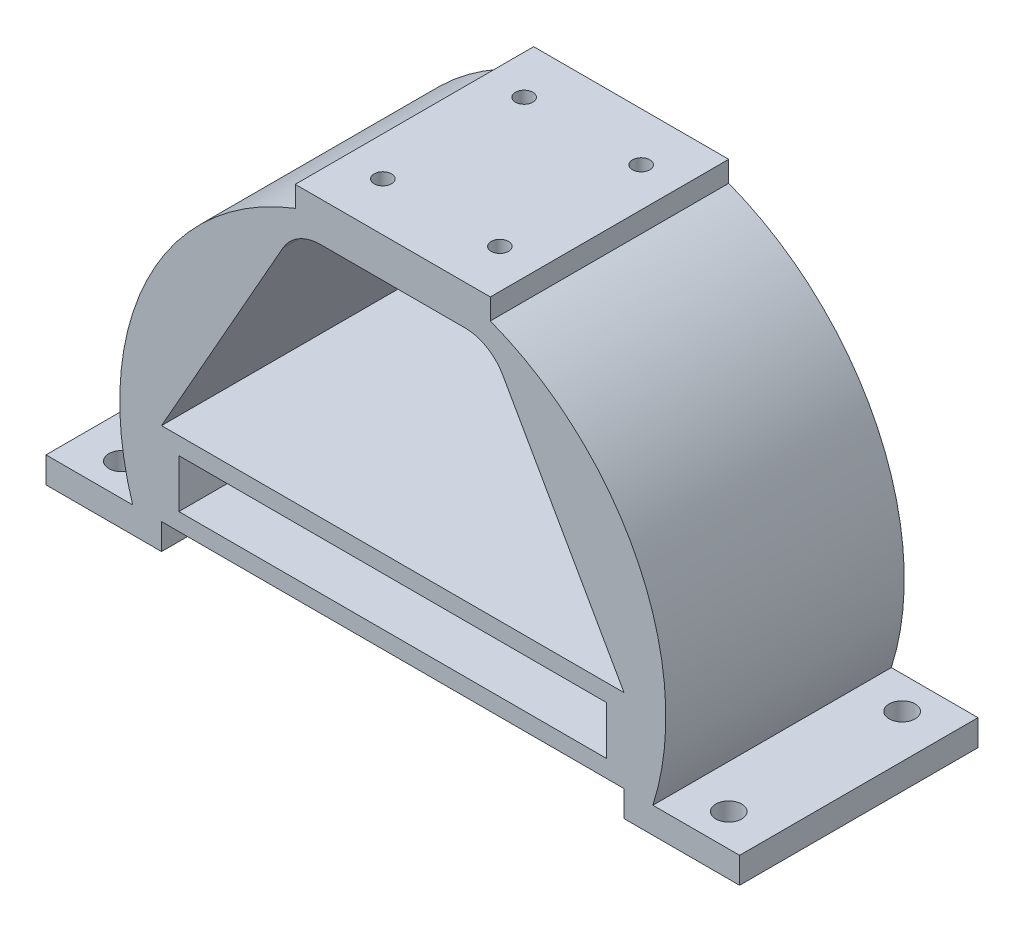
from build123d import *

# Parameters (mm, degrees)
BOSS_EXTRUDE1_DEPTH = 69.85
SKETCH2_W           = 135.505629996
SKETCH2_H           = 24.343701923
SKETCH2_W_2         = 125.345629996
SKETCH2_H_2         = 14.183701923
BOSS_EXTRUDE2_DEPTH = 69.85
CUT_EXTRUDE1_REACH  = 169.093
SKETCH3_R           = 3.81
CUT_EXTRUDE2_REACH  = 169.093
FILLET1_R           = 12.7


with BuildPart() as part:
    # Sketch1 → Boss-Extrude1 (new body)
    with BuildSketch(Plane.XY):
        with BuildLine():
            ThreePointArc((-28.575, 101.213911712), (-14.56545796, 105.448187464), (0, 106.877800601))
            Line((0, 106.877800601), (0, 112.776))
            Line((0, 112.776), (-28.575, 112.776))
            Line((-28.575, 112.776), (-28.575, 106.68))
            ThreePointArc((-28.575, 106.68), (-72.094875381, 66.624699703), (-76.2, 7.62))
            Line((-76.2, 7.62), (-101.6, 7.62))
            Line((-101.6, 7.62), (-101.6, 0))
            Line((-101.6, 0), (-67.752814998, 0))
            ThreePointArc((-67.752814998, 0), (-74.914098678, 31.963701923), (-67.752814998, 63.927403846))
            ThreePointArc((-67.752814998, 63.927403846), (-51.64622835, 86.229614594), (-28.575, 101.213911712))
        make_face()
        with BuildLine():
            Line((67.752814998, 0), (101.6, 0))
            Line((101.6, 0), (101.6, 7.62))
            Line((101.6, 7.62), (76.2, 7.62))
            ThreePointArc((76.2, 7.62), (72.094875381, 66.624699703), (28.575, 106.68))
            Line((28.575, 106.68), (28.575, 112.776))
            Line((28.575, 112.776), (0, 112.776))
            Line((0, 112.776), (0, 106.877800601))
            ThreePointArc((0, 106.877800601), (14.56545796, 105.448187464), (28.575, 101.213911712))
            ThreePointArc((28.575, 101.213911712), (51.64622835, 86.229614594), (67.752814998, 63.927403846))
            ThreePointArc((67.752814998, 63.927403846), (74.914098678, 31.963701923), (67.752814998, 0))
        make_face()
        with BuildLine():
            Line((28.575, 101.213911712), (67.752814998, 31.963701923))
            Line((67.752814998, 31.963701923), (67.752814998, 63.927403846))
            ThreePointArc((67.752814998, 63.927403846), (51.64622835, 86.229614594), (28.575, 101.213911712))
        make_face()
        with BuildLine():
            Line((0, 101.213911712), (28.575, 101.213911712))
            ThreePointArc((28.575, 101.213911712), (14.56545796, 105.448187464), (0, 106.877800601))
            Line((0, 106.877800601), (0, 101.213911712))
        make_face()
        with BuildLine():
            Line((-28.575, 101.213911712), (0, 101.213911712))
            Line((0, 101.213911712), (0, 106.877800601))
            ThreePointArc((0, 106.877800601), (-14.56545796, 105.448187464), (-28.575, 101.213911712))
        make_face()
        with BuildLine():
            Line((-67.752814998, 31.963701923), (-28.575, 101.213911712))
            ThreePointArc((-28.575, 101.213911712), (-51.64622835, 86.229614594), (-67.752814998, 63.927403846))
            Line((-67.752814998, 63.927403846), (-67.752814998, 31.963701923))
        make_face()
        with BuildLine():
            Line((-67.752814998, 0), (-67.752814998, 31.963701923))
            Line((-67.752814998, 31.963701923), (-67.752814998, 63.927403846))
            ThreePointArc((-67.752814998, 63.927403846), (-74.914098678, 31.963701923), (-67.752814998, 0))
        make_face()
        with BuildLine():
            Line((67.752814998, 31.963701923), (67.752814998, 0))
            ThreePointArc((67.752814998, 0), (74.914098678, 31.963701923), (67.752814998, 63.927403846))
            Line((67.752814998, 63.927403846), (67.752814998, 31.963701923))
        make_face()
    extrude(amount=BOSS_EXTRUDE1_DEPTH)

    # Sketch2 → Boss-Extrude2 (add)
    with BuildSketch(Plane.XY.offset(69.85)):
        with Locations((0, 19.791850961)):
            Rectangle(SKETCH2_W, SKETCH2_H)
        with Locations((0, 19.791850961)):
            Rectangle(SKETCH2_W_2, SKETCH2_H_2, mode=Mode.SUBTRACT)
    extrude(amount=-BOSS_EXTRUDE2_DEPTH)

    # Sketch3 → Cut-Extrude1 (cut, up to next)
    with BuildSketch(Plane(origin=(0, 0, 0), x_dir=(-1, 0, 0), z_dir=(0, -1, 0)), mode=Mode.PRIVATE) as cut_extrude1_sk1:
        with Locations(Location((88.9, -60.325, 0), (0, 0, 90))):
            Circle(SKETCH3_R)
    cut_extrude1_tool1 = extrude(cut_extrude1_sk1.sketch, amount=-CUT_EXTRUDE1_REACH, mode=Mode.PRIVATE) & part.part
    # Sketch3 → Cut-Extrude1 (cut, up to next)
    with BuildSketch(Plane(origin=(0, 0, 0), x_dir=(-1, 0, 0), z_dir=(0, -1, 0)), mode=Mode.PRIVATE) as cut_extrude1_sk2:
        with Locations(Location((88.9, -9.525, 0), (0, 0, 90))):
            Circle(SKETCH3_R)
    cut_extrude1_tool2 = extrude(cut_extrude1_sk2.sketch, amount=-CUT_EXTRUDE1_REACH, mode=Mode.PRIVATE) & part.part
    # Sketch3 → Cut-Extrude1 (cut, up to next)
    with BuildSketch(Plane(origin=(0, 0, 0), x_dir=(-1, 0, 0), z_dir=(0, -1, 0)), mode=Mode.PRIVATE) as cut_extrude1_sk3:
        with Locations(Location((-88.9, -9.525, 0), (0, 0, 90))):
            Circle(SKETCH3_R)
    cut_extrude1_tool3 = extrude(cut_extrude1_sk3.sketch, amount=-CUT_EXTRUDE1_REACH, mode=Mode.PRIVATE) & part.part
    # Sketch3 → Cut-Extrude1 (cut, up to next)
    with BuildSketch(Plane(origin=(0, 0, 0), x_dir=(-1, 0, 0), z_dir=(0, -1, 0)), mode=Mode.PRIVATE) as cut_extrude1_sk4:
        with Locations(Location((-88.9, -60.325, 0), (0, 0, 90))):
            Circle(SKETCH3_R)
    cut_extrude1_tool4 = extrude(cut_extrude1_sk4.sketch, amount=-CUT_EXTRUDE1_REACH, mode=Mode.PRIVATE) & part.part
    add(cut_extrude1_tool1.solids().sort_by_distance((-88.9, 0, 60.325))[0], mode=Mode.SUBTRACT)
    add(cut_extrude1_tool2.solids().sort_by_distance((-88.9, 0, 9.525))[0], mode=Mode.SUBTRACT)
    add(cut_extrude1_tool3.solids().sort_by_distance((88.9, 0, 9.525))[0], mode=Mode.SUBTRACT)
    add(cut_extrude1_tool4.solids().sort_by_distance((88.9, 0, 60.325))[0], mode=Mode.SUBTRACT)

    # Sketch4 → Cut-Extrude2 (cut, up to next)
    with BuildSketch(Plane(origin=(0, 112.776, 0), x_dir=(1, 0, 0), z_dir=(0, 1, 0)), mode=Mode.PRIVATE) as cut_extrude2_sk1:
        with BuildLine():
            ThreePointArc((-14.605, -14.224), (-18.941051224, -12.427948776), (-17.145, -16.764))
            Line((-17.145, -16.764), (-17.145, -14.224))
            Line((-17.145, -14.224), (-14.605, -14.224))
        make_face()
    cut_extrude2_tool1 = extrude(cut_extrude2_sk1.sketch, amount=-CUT_EXTRUDE2_REACH, mode=Mode.PRIVATE) & part.part
    # Sketch4 → Cut-Extrude2 (cut, up to next)
    with BuildSketch(Plane(origin=(0, 112.776, 0), x_dir=(1, 0, 0), z_dir=(0, 1, 0)), mode=Mode.PRIVATE) as cut_extrude2_sk2:
        with BuildLine():
            Line((-17.145, -14.224), (-17.145, -16.764))
            ThreePointArc((-17.145, -16.764), (-15.348948776, -16.020051224), (-14.605, -14.224))
            Line((-14.605, -14.224), (-17.145, -14.224))
        make_face()
    cut_extrude2_tool2 = extrude(cut_extrude2_sk2.sketch, amount=-CUT_EXTRUDE2_REACH, mode=Mode.PRIVATE) & part.part
    # Sketch4 → Cut-Extrude2 (cut, up to next)
    with BuildSketch(Plane(origin=(0, 112.776, 0), x_dir=(1, 0, 0), z_dir=(0, 1, 0)), mode=Mode.PRIVATE) as cut_extrude2_sk3:
        with BuildLine():
            ThreePointArc((14.605, -14.224), (15.348948776, -16.020051224), (17.145, -16.764))
            Line((17.145, -16.764), (17.145, -14.224))
            Line((17.145, -14.224), (14.605, -14.224))
        make_face()
    cut_extrude2_tool3 = extrude(cut_extrude2_sk3.sketch, amount=-CUT_EXTRUDE2_REACH, mode=Mode.PRIVATE) & part.part
    # Sketch4 → Cut-Extrude2 (cut, up to next)
    with BuildSketch(Plane(origin=(0, 112.776, 0), x_dir=(1, 0, 0), z_dir=(0, 1, 0)), mode=Mode.PRIVATE) as cut_extrude2_sk4:
        with BuildLine():
            Line((17.145, -14.224), (17.145, -16.764))
            ThreePointArc((17.145, -16.764), (18.941051224, -16.020051224), (19.685, -14.224))
            ThreePointArc((19.685, -14.224), (17.145, -11.684), (14.605, -14.224))
            Line((14.605, -14.224), (17.145, -14.224))
        make_face()
    cut_extrude2_tool4 = extrude(cut_extrude2_sk4.sketch, amount=-CUT_EXTRUDE2_REACH, mode=Mode.PRIVATE) & part.part
    # Sketch4 → Cut-Extrude2 (cut, up to next)
    with BuildSketch(Plane(origin=(0, 112.776, 0), x_dir=(1, 0, 0), z_dir=(0, 1, 0)), mode=Mode.PRIVATE) as cut_extrude2_sk5:
        with BuildLine():
            ThreePointArc((17.145, -53.086), (15.348948776, -53.829948776), (14.605, -55.626))
            Line((14.605, -55.626), (17.145, -55.626))
            Line((17.145, -55.626), (17.145, -53.086))
        make_face()
    cut_extrude2_tool5 = extrude(cut_extrude2_sk5.sketch, amount=-CUT_EXTRUDE2_REACH, mode=Mode.PRIVATE) & part.part
    # Sketch4 → Cut-Extrude2 (cut, up to next)
    with BuildSketch(Plane(origin=(0, 112.776, 0), x_dir=(1, 0, 0), z_dir=(0, 1, 0)), mode=Mode.PRIVATE) as cut_extrude2_sk6:
        with BuildLine():
            Line((17.145, -55.626), (14.605, -55.626))
            ThreePointArc((14.605, -55.626), (17.145, -58.166), (19.685, -55.626))
            ThreePointArc((19.685, -55.626), (18.941051224, -53.829948776), (17.145, -53.086))
            Line((17.145, -53.086), (17.145, -55.626))
        make_face()
    cut_extrude2_tool6 = extrude(cut_extrude2_sk6.sketch, amount=-CUT_EXTRUDE2_REACH, mode=Mode.PRIVATE) & part.part
    # Sketch4 → Cut-Extrude2 (cut, up to next)
    with BuildSketch(Plane(origin=(0, 112.776, 0), x_dir=(1, 0, 0), z_dir=(0, 1, 0)), mode=Mode.PRIVATE) as cut_extrude2_sk7:
        with BuildLine():
            ThreePointArc((-17.145, -53.086), (-18.941051224, -57.422051224), (-14.605, -55.626))
            Line((-14.605, -55.626), (-17.145, -55.626))
            Line((-17.145, -55.626), (-17.145, -53.086))
        make_face()
    cut_extrude2_tool7 = extrude(cut_extrude2_sk7.sketch, amount=-CUT_EXTRUDE2_REACH, mode=Mode.PRIVATE) & part.part
    # Sketch4 → Cut-Extrude2 (cut, up to next)
    with BuildSketch(Plane(origin=(0, 112.776, 0), x_dir=(1, 0, 0), z_dir=(0, 1, 0)), mode=Mode.PRIVATE) as cut_extrude2_sk8:
        with BuildLine():
            Line((-17.145, -55.626), (-14.605, -55.626))
            ThreePointArc((-14.605, -55.626), (-15.348948776, -53.829948776), (-17.145, -53.086))
            Line((-17.145, -53.086), (-17.145, -55.626))
        make_face()
    cut_extrude2_tool8 = extrude(cut_extrude2_sk8.sketch, amount=-CUT_EXTRUDE2_REACH, mode=Mode.PRIVATE) & part.part
    # Sketch4 → Cut-Extrude2 (cut, up to next)
    with BuildSketch(Plane(origin=(0, 112.776, 0), x_dir=(1, 0, 0), z_dir=(0, 1, 0)), mode=Mode.PRIVATE) as cut_extrude2_sk9:
        with BuildLine():
            ThreePointArc((-17.145, -53.086), (-18.941051224, -57.422051224), (-14.605, -55.626))
            Line((-14.605, -55.626), (-17.145, -55.626))
            Line((-17.145, -55.626), (-17.145, -53.086))
        make_face()
    cut_extrude2_tool9 = extrude(cut_extrude2_sk9.sketch, amount=-CUT_EXTRUDE2_REACH, mode=Mode.PRIVATE) & part.part
    # Sketch4 → Cut-Extrude2 (cut, up to next)
    with BuildSketch(Plane(origin=(0, 112.776, 0), x_dir=(1, 0, 0), z_dir=(0, 1, 0)), mode=Mode.PRIVATE) as cut_extrude2_sk10:
        with BuildLine():
            Line((-17.145, -55.626), (-14.605, -55.626))
            ThreePointArc((-14.605, -55.626), (-15.348948776, -53.829948776), (-17.145, -53.086))
            Line((-17.145, -53.086), (-17.145, -55.626))
        make_face()
    cut_extrude2_tool10 = extrude(cut_extrude2_sk10.sketch, amount=-CUT_EXTRUDE2_REACH, mode=Mode.PRIVATE) & part.part
    # Sketch4 → Cut-Extrude2 (cut, up to next)
    with BuildSketch(Plane(origin=(0, 112.776, 0), x_dir=(1, 0, 0), z_dir=(0, 1, 0)), mode=Mode.PRIVATE) as cut_extrude2_sk11:
        with BuildLine():
            ThreePointArc((-14.605, -14.224), (-18.941051224, -12.427948776), (-17.145, -16.764))
            Line((-17.145, -16.764), (-17.145, -14.224))
            Line((-17.145, -14.224), (-14.605, -14.224))
        make_face()
    cut_extrude2_tool11 = extrude(cut_extrude2_sk11.sketch, amount=-CUT_EXTRUDE2_REACH, mode=Mode.PRIVATE) & part.part
    # Sketch4 → Cut-Extrude2 (cut, up to next)
    with BuildSketch(Plane(origin=(0, 112.776, 0), x_dir=(1, 0, 0), z_dir=(0, 1, 0)), mode=Mode.PRIVATE) as cut_extrude2_sk12:
        with BuildLine():
            Line((-17.145, -14.224), (-17.145, -16.764))
            ThreePointArc((-17.145, -16.764), (-15.348948776, -16.020051224), (-14.605, -14.224))
            Line((-14.605, -14.224), (-17.145, -14.224))
        make_face()
    cut_extrude2_tool12 = extrude(cut_extrude2_sk12.sketch, amount=-CUT_EXTRUDE2_REACH, mode=Mode.PRIVATE) & part.part
    # Sketch4 → Cut-Extrude2 (cut, up to next)
    with BuildSketch(Plane(origin=(0, 112.776, 0), x_dir=(1, 0, 0), z_dir=(0, 1, 0)), mode=Mode.PRIVATE) as cut_extrude2_sk13:
        with BuildLine():
            ThreePointArc((14.605, -14.224), (15.348948776, -16.020051224), (17.145, -16.764))
            Line((17.145, -16.764), (17.145, -14.224))
            Line((17.145, -14.224), (14.605, -14.224))
        make_face()
    cut_extrude2_tool13 = extrude(cut_extrude2_sk13.sketch, amount=-CUT_EXTRUDE2_REACH, mode=Mode.PRIVATE) & part.part
    # Sketch4 → Cut-Extrude2 (cut, up to next)
    with BuildSketch(Plane(origin=(0, 112.776, 0), x_dir=(1, 0, 0), z_dir=(0, 1, 0)), mode=Mode.PRIVATE) as cut_extrude2_sk14:
        with BuildLine():
            Line((17.145, -14.224), (17.145, -16.764))
            ThreePointArc((17.145, -16.764), (18.941051224, -16.020051224), (19.685, -14.224))
            ThreePointArc((19.685, -14.224), (17.145, -11.684), (14.605, -14.224))
            Line((14.605, -14.224), (17.145, -14.224))
        make_face()
    cut_extrude2_tool14 = extrude(cut_extrude2_sk14.sketch, amount=-CUT_EXTRUDE2_REACH, mode=Mode.PRIVATE) & part.part
    # Sketch4 → Cut-Extrude2 (cut, up to next)
    with BuildSketch(Plane(origin=(0, 112.776, 0), x_dir=(1, 0, 0), z_dir=(0, 1, 0)), mode=Mode.PRIVATE) as cut_extrude2_sk15:
        with BuildLine():
            ThreePointArc((17.145, -53.086), (15.348948776, -53.829948776), (14.605, -55.626))
            Line((14.605, -55.626), (17.145, -55.626))
            Line((17.145, -55.626), (17.145, -53.086))
        make_face()
    cut_extrude2_tool15 = extrude(cut_extrude2_sk15.sketch, amount=-CUT_EXTRUDE2_REACH, mode=Mode.PRIVATE) & part.part
    # Sketch4 → Cut-Extrude2 (cut, up to next)
    with BuildSketch(Plane(origin=(0, 112.776, 0), x_dir=(1, 0, 0), z_dir=(0, 1, 0)), mode=Mode.PRIVATE) as cut_extrude2_sk16:
        with BuildLine():
            Line((17.145, -55.626), (14.605, -55.626))
            ThreePointArc((14.605, -55.626), (17.145, -58.166), (19.685, -55.626))
            ThreePointArc((19.685, -55.626), (18.941051224, -53.829948776), (17.145, -53.086))
            Line((17.145, -53.086), (17.145, -55.626))
        make_face()
    cut_extrude2_tool16 = extrude(cut_extrude2_sk16.sketch, amount=-CUT_EXTRUDE2_REACH, mode=Mode.PRIVATE) & part.part
    add(cut_extrude2_tool1.solids().sort_by_distance((-17.504336, 112.776, 13.864664))[0], mode=Mode.SUBTRACT)
    add(cut_extrude2_tool2.solids().sort_by_distance((-16.066991, 112.776, 15.302009))[0], mode=Mode.SUBTRACT)
    add(cut_extrude2_tool3.solids().sort_by_distance((16.066991, 112.776, 15.302009))[0], mode=Mode.SUBTRACT)
    add(cut_extrude2_tool4.solids().sort_by_distance((17.504336, 112.776, 13.864664))[0], mode=Mode.SUBTRACT)
    add(cut_extrude2_tool5.solids().sort_by_distance((16.066991, 112.776, 54.547991))[0], mode=Mode.SUBTRACT)
    add(cut_extrude2_tool6.solids().sort_by_distance((17.504336, 112.776, 55.985336))[0], mode=Mode.SUBTRACT)
    add(cut_extrude2_tool7.solids().sort_by_distance((-17.504336, 112.776, 55.985336))[0], mode=Mode.SUBTRACT)
    add(cut_extrude2_tool8.solids().sort_by_distance((-16.066991, 112.776, 54.547991))[0], mode=Mode.SUBTRACT)
    add(cut_extrude2_tool9.solids().sort_by_distance((-17.504336, 112.776, 55.985336))[0], mode=Mode.SUBTRACT)
    add(cut_extrude2_tool10.solids().sort_by_distance((-16.066991, 112.776, 54.547991))[0], mode=Mode.SUBTRACT)
    add(cut_extrude2_tool11.solids().sort_by_distance((-17.504336, 112.776, 13.864664))[0], mode=Mode.SUBTRACT)
    add(cut_extrude2_tool12.solids().sort_by_distance((-16.066991, 112.776, 15.302009))[0], mode=Mode.SUBTRACT)
    add(cut_extrude2_tool13.solids().sort_by_distance((16.066991, 112.776, 15.302009))[0], mode=Mode.SUBTRACT)
    add(cut_extrude2_tool14.solids().sort_by_distance((17.504336, 112.776, 13.864664))[0], mode=Mode.SUBTRACT)
    add(cut_extrude2_tool15.solids().sort_by_distance((16.066991, 112.776, 54.547991))[0], mode=Mode.SUBTRACT)
    add(cut_extrude2_tool16.solids().sort_by_distance((17.504336, 112.776, 55.985336))[0], mode=Mode.SUBTRACT)

    # Fillet1
    fillet1_edges = [part.edges().sort_by_distance(p)[0] for p in [
        (28.575, 101.213911712, 34.925),
        (-28.575, 101.213911712, 34.925),
    ]]
    fillet(fillet1_edges, radius=FILLET1_R)


solid = part.part
